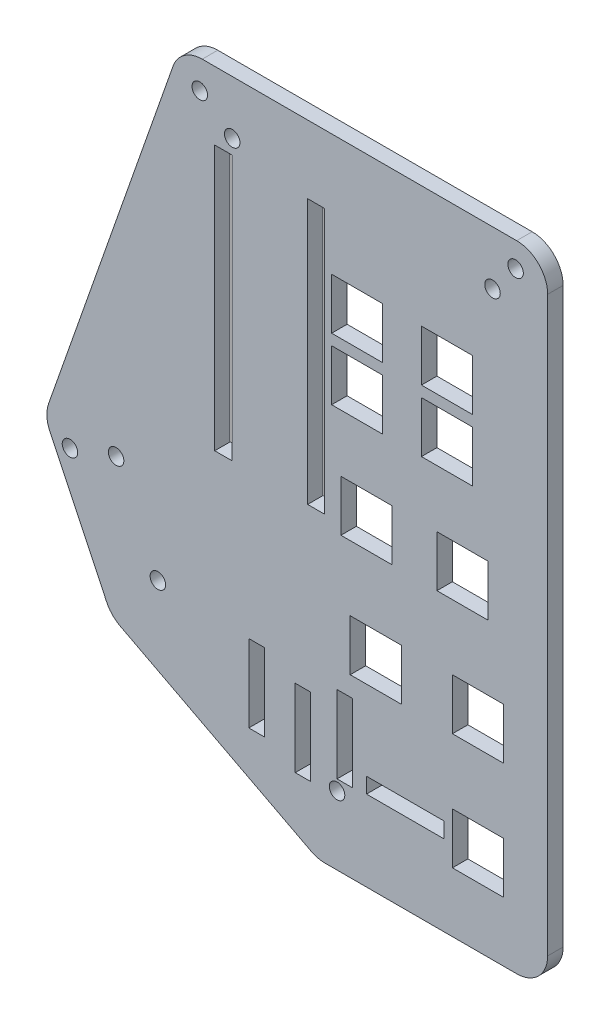
from build123d import *

# Parameters (mm, degrees)
SKETCH1_R           = 1.27
BOSS_EXTRUDE1_DEPTH = 2.54
SKETCH5_W           = 8.382
SKETCH5_H           = 8.382
SKETCH5_W_2         = 2.794
SKETCH5_H_2         = 43.434
CUT_EXTRUDE1_DEPTH  = 3.54
SKETCH7_R           = 1.27
CUT_EXTRUDE3_DEPTH  = 3.54
SKETCH8_W           = 12.7
SKETCH8_H           = 2.54
SKETCH8_W_2         = 2.54
SKETCH8_H_2         = 12.7
CUT_EXTRUDE4_DEPTH  = 3.54


with BuildPart() as part:
    # Sketch1 → Boss-Extrude1 (new body)
    with BuildSketch(Plane.XY):
        with BuildLine():
            Line((-3.314058103, 6.35), (48.26, 6.35))
            ThreePointArc((48.26, 6.35), (51.852102448, 4.862102448), (53.34, 1.27))
            Line((53.34, 1.27), (53.34, -92.71))
            ThreePointArc((53.34, -92.71), (51.852102448, -96.302102448), (48.26, -97.79))
            Line((48.26, -97.79), (16.846989059, -97.79))
            ThreePointArc((16.846989059, -97.79), (15.638688158, -97.644208035), (14.499741809, -97.215200367))
            Line((14.499741809, -97.215200367), (-16.7505185, -80.933552139))
            ThreePointArc((-16.7505185, -80.933552139), (-18.059258376, -79.955412607), (-18.989802686, -78.61241436))
            Line((-18.989802686, -78.61241436), (-28.309569459, -59.040904135))
            ThreePointArc((-28.309569459, -59.040904135), (-28.795802898, -57.127870198), (-28.51617555, -55.173917704))
            Line((-28.51617555, -55.173917704), (-8.107195629, 2.952923842))
            ThreePointArc((-8.107195629, 2.952923842), (-6.251501454, 5.414614163), (-3.314058103, 6.35))
        make_face()
        with Locations((48.0822, 2.286)):
            Circle(SKETCH1_R, mode=Mode.SUBTRACT)
        with Locations((-3.718687848, 1.651)):
            Circle(SKETCH1_R, mode=Mode.SUBTRACT)
        with Locations((-25.012261453, -59.761967182)):
            Circle(SKETCH1_R, mode=Mode.SUBTRACT)
    extrude(amount=BOSS_EXTRUDE1_DEPTH)

    # Sketch5 → Cut-Extrude1 (cut, through all)
    with BuildSketch(Plane(origin=(0, 0, 0), x_dir=(-1, 0, 0), z_dir=(0, 0, -1))):
        with Locations((-36.83, -17.78)):
            Rectangle(SKETCH5_W, SKETCH5_H)
        with Locations((-39.37, -45.72)):
            Rectangle(SKETCH5_W, SKETCH5_H)
        with Locations((-36.83, -27.94)):
            Rectangle(SKETCH5_W, SKETCH5_H)
        with Locations((-41.91, -64.77)):
            Rectangle(SKETCH5_W, SKETCH5_H)
        with Locations((-41.91, -83.82)):
            Rectangle(SKETCH5_W, SKETCH5_H)
        with Locations((-22.098, -17.78)):
            Rectangle(SKETCH5_W, SKETCH5_H)
        with Locations((-22.098, -27.94)):
            Rectangle(SKETCH5_W, SKETCH5_H)
        with Locations((-23.622, -45.72)):
            Rectangle(SKETCH5_W, SKETCH5_H)
        with Locations((-25.146, -64.77)):
            Rectangle(SKETCH5_W, SKETCH5_H)
        with Locations((-15.367, -26.543)):
            Rectangle(SKETCH5_W_2, SKETCH5_H_2)
        with Locations((-0.127, -26.543)):
            Rectangle(SKETCH5_W_2, SKETCH5_H_2)
    extrude(amount=-CUT_EXTRUDE1_DEPTH, mode=Mode.SUBTRACT)

    # Sketch7 → Cut-Extrude3 (cut, through all)
    with BuildSketch(Plane.XY.offset(2.54)):
        with Locations((44.2976, -2.4892)):
            Circle(SKETCH7_R)
        with Locations((1.6002, -2.4384)):
            Circle(SKETCH7_R)
        with Locations((-17.4498, -57.15)):
            Circle(SKETCH7_R)
        with Locations((-10.5918, -71.3486)):
            Circle(SKETCH7_R)
        with Locations((18.796, -86.5378)):
            Circle(SKETCH7_R)
    extrude(amount=-CUT_EXTRUDE3_DEPTH, mode=Mode.SUBTRACT)

    # Sketch8 → Cut-Extrude4 (cut, through all)
    with BuildSketch(Plane.XY.offset(2.54)):
        with Locations((29.972, -83.312)):
            Rectangle(SKETCH8_W, SKETCH8_H)
        with Locations((20.066, -78.486)):
            Rectangle(SKETCH8_W_2, SKETCH8_H_2)
        with Locations((13.208, -81.026)):
            Rectangle(SKETCH8_W_2, SKETCH8_H_2)
        with Locations((5.588, -78.486)):
            Rectangle(SKETCH8_W_2, SKETCH8_H_2)
    extrude(amount=-CUT_EXTRUDE4_DEPTH, mode=Mode.SUBTRACT)


solid = part.part
